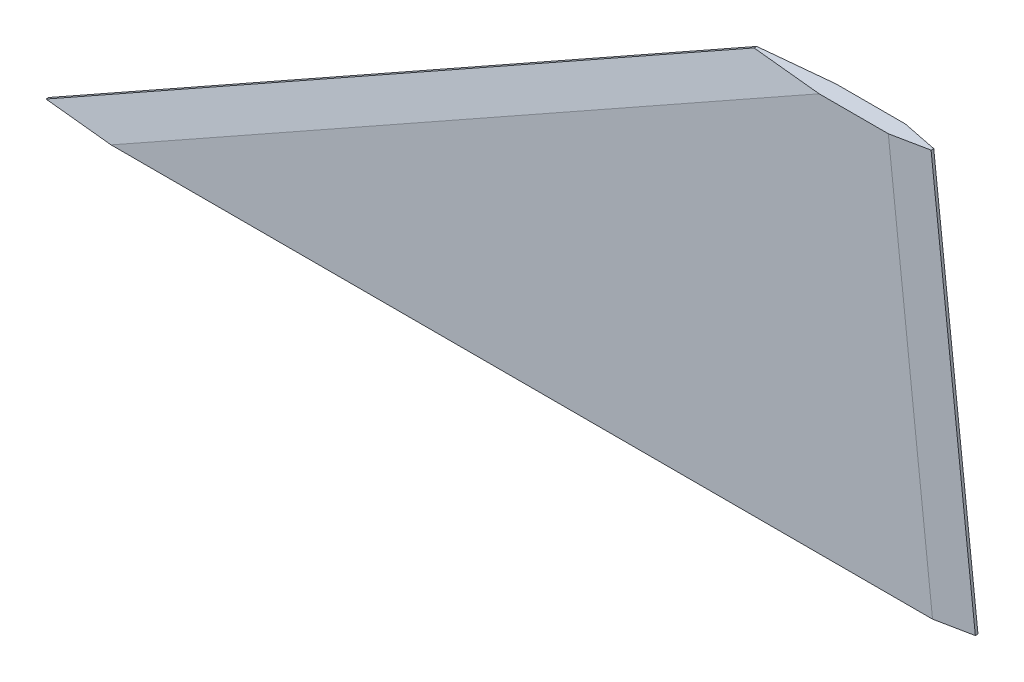
from build123d import *

# Parameters (mm, degrees)
BOSS_EXTRUDE1_DEPTH   = 1.2192
CHAMFER1_SIZE         = 5.08
CHAMFER1_SIZE2        = 1.0287
CHAMFER1_PART_2_SIZE  = 5.08
CHAMFER1_PART_2_SIZE2 = 1.0287
CHAMFER2_SIZE         = 5.08
CHAMFER2_SIZE2        = 1.0287
CHAMFER2_PART_2_SIZE  = 5.08
CHAMFER2_PART_2_SIZE2 = 1.0287


with BuildPart() as part:
    # Sketch1 → Boss-Extrude1 (new body, symmetric)
    with BuildSketch(Plane.XY):
        Polygon((0, 0), (101.6, 57.15), (127, 57.15), (133.35, 0), align=None)
    extrude(amount=BOSS_EXTRUDE1_DEPTH, both=True)

    # Chamfer1
    chamfer1_edges = [part.edges().sort_by_distance(p)[0] for p in [
        (50.8, 28.575, 1.2192),
    ]]
    chamfer1_side = [part.faces().sort_by_distance(p)[0] for p in [
        (85.09, 22.098, 1.2192),
    ]]
    chamfer(chamfer1_edges, length=CHAMFER1_SIZE, length2=CHAMFER1_SIZE2, reference=chamfer1_side[0])

    # Chamfer1 part 2
    chamfer1_part_2_edges = [part.edges().sort_by_distance(p)[0] for p in [
        (50.8, 28.575, -1.2192),
    ]]
    chamfer1_part_2_side = [part.faces().sort_by_distance(p)[0] for p in [
        (85.09, 22.098, -1.2192),
    ]]
    chamfer(chamfer1_part_2_edges, length=CHAMFER1_PART_2_SIZE, length2=CHAMFER1_PART_2_SIZE2, reference=chamfer1_part_2_side[0])

    # Chamfer2
    chamfer2_edges = [part.edges().sort_by_distance(p)[0] for p in [
        (130.175, 28.575, -1.2192),
    ]]
    chamfer2_side = [part.faces().sort_by_distance(p)[0] for p in [
        (89.460516254, 21.125525936, -1.2192),
    ]]
    chamfer(chamfer2_edges, length=CHAMFER2_SIZE, length2=CHAMFER2_SIZE2, reference=chamfer2_side[0])

    # Chamfer2 part 2
    chamfer2_part_2_edges = [part.edges().sort_by_distance(p)[0] for p in [
        (130.175, 28.575, 1.2192),
    ]]
    chamfer2_part_2_side = [part.faces().sort_by_distance(p)[0] for p in [
        (89.460516254, 21.125525936, 1.2192),
    ]]
    chamfer(chamfer2_part_2_edges, length=CHAMFER2_PART_2_SIZE, length2=CHAMFER2_PART_2_SIZE2, reference=chamfer2_part_2_side[0])


solid = part.part
